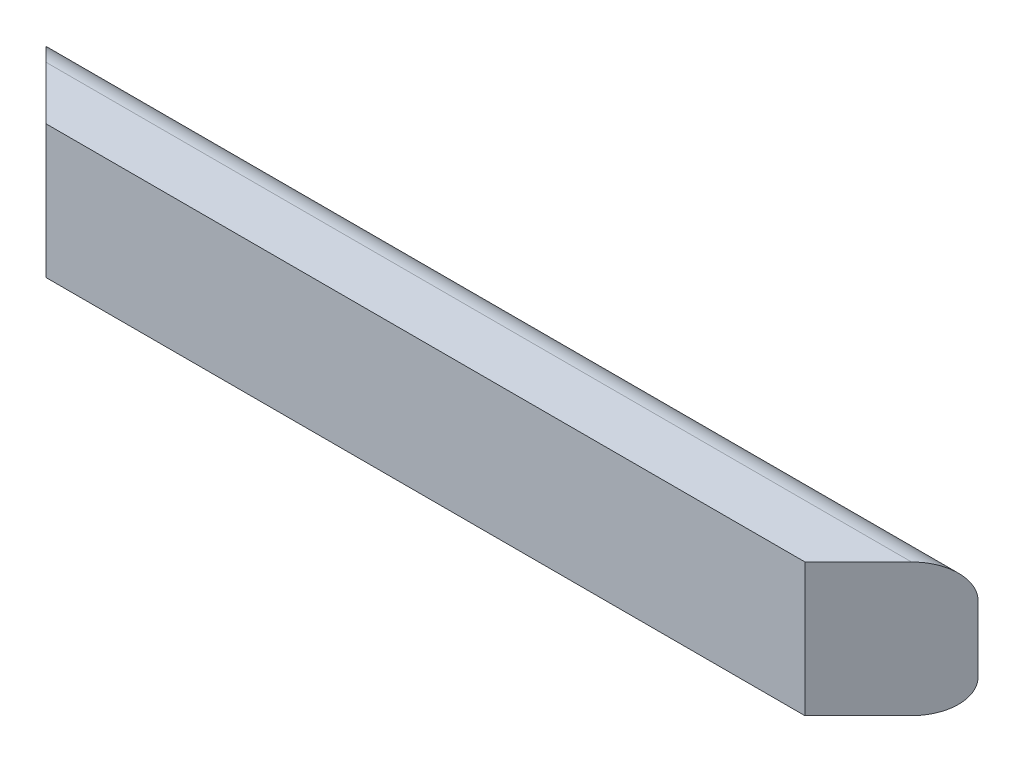
from build123d import *

# Parameters (mm, degrees)
BOSS_EXTRUDE1_DEPTH = 888.6444
SKETCH2_W           = 344.402501539
SKETCH2_H           = 780.457540958
CUT_EXTRUDE1_DEPTH  = 59.371664787


with BuildPart() as part:
    # Sketch1 → Boss-Extrude1 (new body)
    with BuildSketch(Plane(origin=(0, 0, 0), x_dir=(0, 0, -1), z_dir=(1, 0, 0))):
        with BuildLine():
            Line((0, 0), (31.75, 0))
            ThreePointArc((31.75, 0), (54.200640303, 9.299359697), (63.5, 31.75))
            Line((63.5, 31.75), (63.5, 95.25))
            ThreePointArc((63.5, 95.25), (54.200640303, 117.700640303), (31.75, 127))
            Line((31.75, 127), (0, 127))
            Line((0, 127), (-19.05, 127))
            Line((-19.05, 127), (-19.05, 0))
            Line((-19.05, 0), (0, 0))
        make_face()
    extrude(amount=BOSS_EXTRUDE1_DEPTH)

    # Sketch2 → Cut-Extrude1 (cut, through all)
    with BuildSketch(Plane(origin=(412.5722, 0, 412.5722), x_dir=(0, 1, 0), z_dir=(0.707106781, 0, 0.707106781))):
        with Locations((32.995160032, -673.267761909)):
            Rectangle(SKETCH2_W, SKETCH2_H)
    cut_extrude1 = extrude(amount=CUT_EXTRUDE1_DEPTH, mode=Mode.SUBTRACT)

    # Mirror1: Cut-Extrude1 across plane
    add(cut_extrude1.mirror(Plane(origin=(444.3222, 0, 0), x_dir=(0, 0, 1), z_dir=(1, 0, 0))), mode=Mode.SUBTRACT)


solid = part.part
